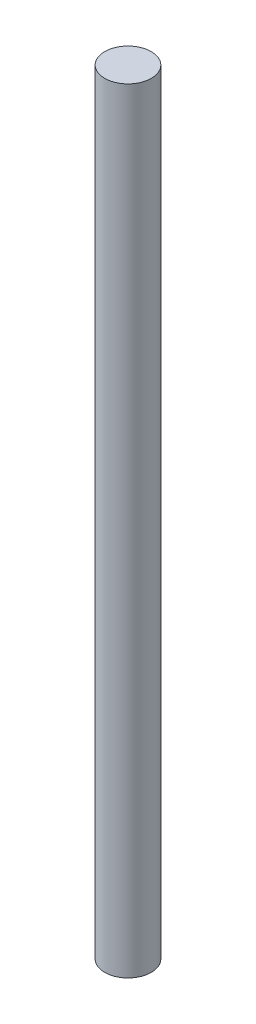
from build123d import *

# Parameters (mm, degrees)
SKETCH1_R           = 0.3
BOSS_EXTRUDE1_DEPTH = 10


with BuildPart() as part:
    # Sketch1 → Boss-Extrude1 (new body)
    with BuildSketch(Plane(origin=(0, 0, 0), x_dir=(1, 0, 0), z_dir=(0, 1, 0))):
        Circle(SKETCH1_R)
    extrude(amount=BOSS_EXTRUDE1_DEPTH)


solid = part.part
